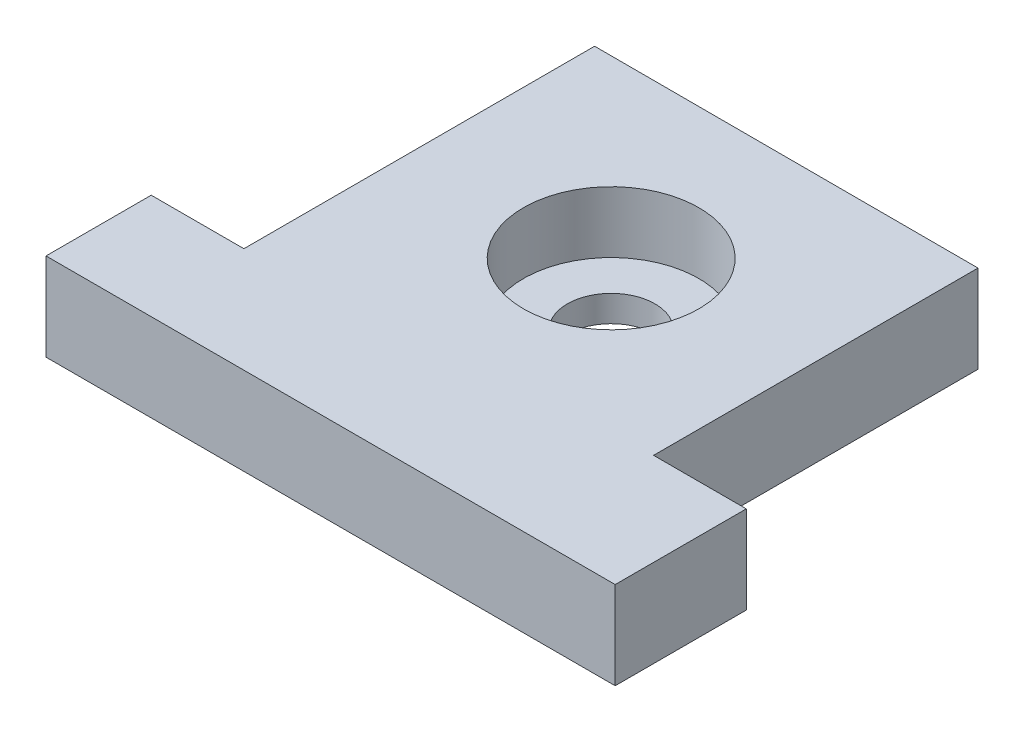
from build123d import *

# Parameters (mm, degrees)
BOSS_EXTRUDE1_DEPTH = 10
SKETCH2_R           = 10
CUT_EXTRUDE2_DEPTH  = 7
SKETCH5_R           = 5
CUT_EXTRUDE3_DEPTH  = 4


with BuildPart() as part:
    # Sketch1 → Boss-Extrude1 (new body)
    with BuildSketch(Plane(origin=(0, 0, 0), x_dir=(1, 0, 0), z_dir=(0, 1, 0))):
        Polygon((-21.887133372, 52), (21.887133372, 51.952432224), (21.887133372, 14.952432224), (32.458561943, 14.952432224), (32.458561943, 0), (-32.458561943, 0), (-32.458561943, 12), (-21.887133372, 12), align=None)
    extrude(amount=BOSS_EXTRUDE1_DEPTH)

    # Sketch2 → Cut-Extrude2 (cut)
    with BuildSketch(Plane(origin=(0, 10, 0), x_dir=(1, 0, 0), z_dir=(0, 1, 0))):
        with Locations((0, 32)):
            Circle(SKETCH2_R)
    extrude(amount=-CUT_EXTRUDE2_DEPTH, mode=Mode.SUBTRACT)

    # Sketch5 → Cut-Extrude3 (cut, through all)
    with BuildSketch(Plane(origin=(0, 3, 0), x_dir=(1, 0, 0), z_dir=(0, 1, 0))):
        with Locations((0, 32)):
            Circle(SKETCH5_R)
    extrude(amount=-CUT_EXTRUDE3_DEPTH, mode=Mode.SUBTRACT)


solid = part.part
